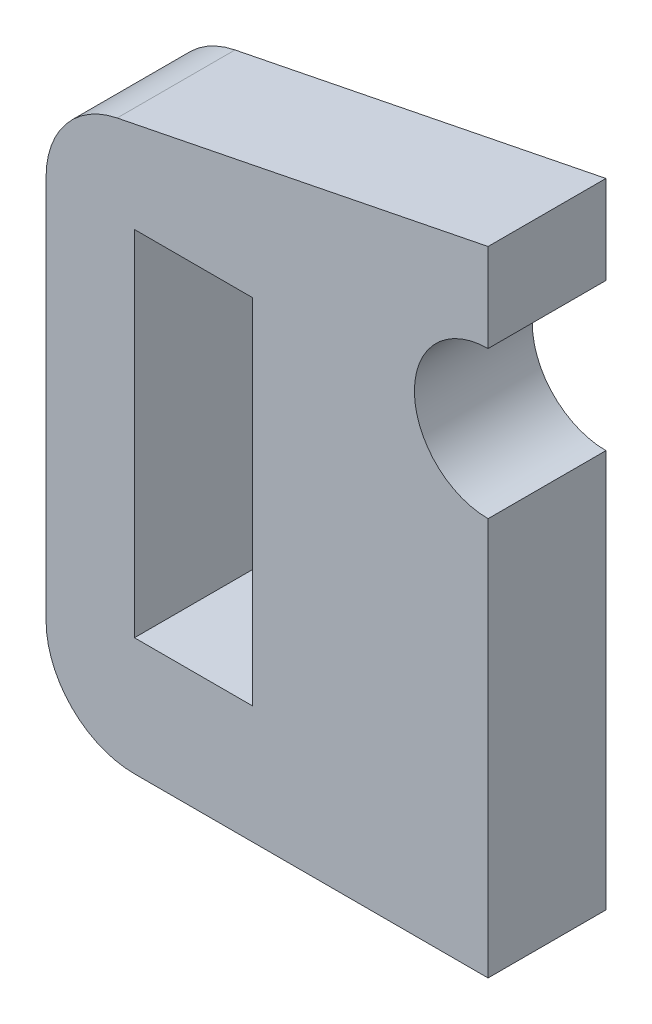
from build123d import *

# Parameters (mm, degrees)
SKETCH_1_W      = 4
SKETCH_1_H      = 12
EXTRUDE_1_DEPTH = 4
FILLET_1_R      = 3


with BuildPart() as part:
    # ｽｹｯﾁ1 → ﾎﾞｽ - 押し出し1 (new body)
    with BuildSketch(Plane.XY):
        with BuildLine():
            Line((0, 2.5), (0, 5.5))
            Line((0, 5.5), (-15, 2.5))
            Line((-15, 2.5), (-15, -16))
            Line((-15, -16), (0, -16))
            Line((0, -16), (0, -2.5))
            ThreePointArc((0, -2.5), (-2.5, 0), (0, 2.5))
        make_face()
        with Locations((-10, -6)):
            Rectangle(SKETCH_1_W, SKETCH_1_H, mode=Mode.SUBTRACT)
    extrude(amount=EXTRUDE_1_DEPTH)

    # ﾌｨﾚｯﾄ1
    fillet_1_edges = [part.edges().sort_by_distance(p)[0] for p in [
        (-15, -16, 2),
        (-15, 2.5, 2),
    ]]
    fillet(fillet_1_edges, radius=FILLET_1_R)


solid = part.part
